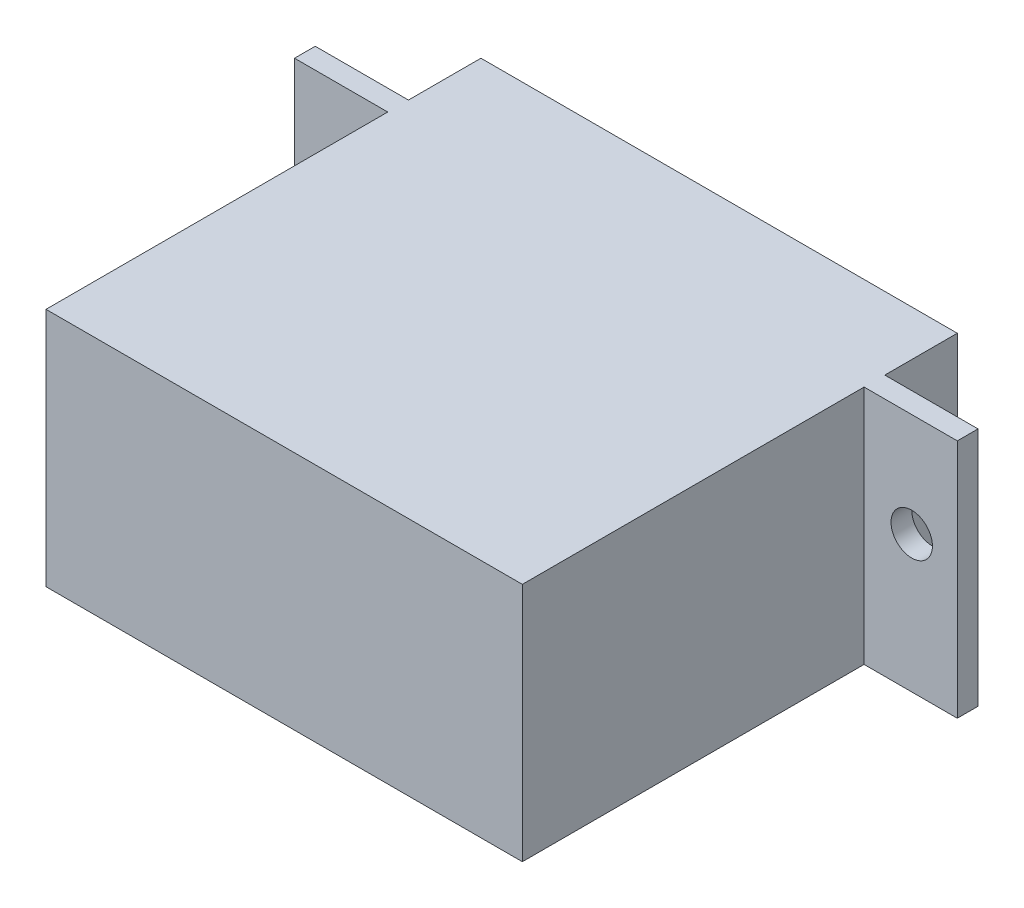
from build123d import *

# Parameters (mm, degrees)
SKETCH1_W           = 23
SKETCH1_H           = 21
BOSS_EXTRUDE1_DEPTH = 11.6
SKETCH2_W           = 1
SKETCH2_H           = 11.6
BOSS_EXTRUDE2_DEPTH = 4.5
SKETCH3_R           = 2
SKETCH3_R_2         = 0.6
BOSS_EXTRUDE3_DEPTH = 3.7
SKETCH4_R           = 1
CUT_EXTRUDE1_DEPTH  = 5


with BuildPart() as part:
    # Sketch1 → Boss-Extrude1 (new body)
    with BuildSketch(Plane(origin=(0, 0, 0), x_dir=(1, 0, 0), z_dir=(0, 1, 0))):
        Rectangle(SKETCH1_W, SKETCH1_H)
    extrude(amount=BOSS_EXTRUDE1_DEPTH)

    # Sketch2 → Boss-Extrude2 (add)
    with BuildSketch(Plane(origin=(11.5, 0, 0), x_dir=(0, 0, -1), z_dir=(1, 0, 0))):
        with Locations((6.5, 5.8)):
            Rectangle(SKETCH2_W, SKETCH2_H)
    boss_extrude2 = extrude(amount=BOSS_EXTRUDE2_DEPTH)

    # Mirror1: Boss-Extrude2 across plane
    add(boss_extrude2.mirror(Plane(origin=(0, 0, 0), x_dir=(0, 0, 1), z_dir=(1, 0, 0))))

    # Sketch3 → Boss-Extrude3 (add)
    with BuildSketch(Plane(origin=(0, 0, -10.5), x_dir=(-1, 0, 0), z_dir=(0, 0, -1))):
        with Locations((-5.5, 5.8)):
            Circle(SKETCH3_R)
        with Locations((-5.5, 5.8)):
            Circle(SKETCH3_R_2, mode=Mode.SUBTRACT)
    extrude(amount=BOSS_EXTRUDE3_DEPTH)

    # Sketch4 → Cut-Extrude1 (cut)
    with BuildSketch(Plane(origin=(0, 0, -7), x_dir=(-1, 0, 0), z_dir=(0, 0, -1))):
        with Locations((-13.8, 6.6)):
            Circle(SKETCH4_R)
        with Locations((13.8, 6.6)):
            Circle(SKETCH4_R)
    extrude(amount=-CUT_EXTRUDE1_DEPTH, mode=Mode.SUBTRACT)


solid = part.part
